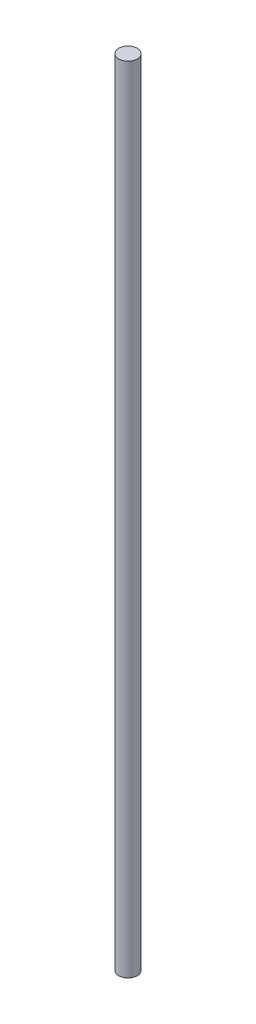
from build123d import *

# Parameters (mm, degrees)
SKETCH1_R           = 2.38125
BOSS_EXTRUDE1_DEPTH = 203.2


with BuildPart() as part:
    # Sketch1 → Boss-Extrude1 (new body)
    with BuildSketch(Plane(origin=(0, 0, 0), x_dir=(1, 0, 0), z_dir=(0, 1, 0))):
        Circle(SKETCH1_R)
    extrude(amount=BOSS_EXTRUDE1_DEPTH)


solid = part.part
